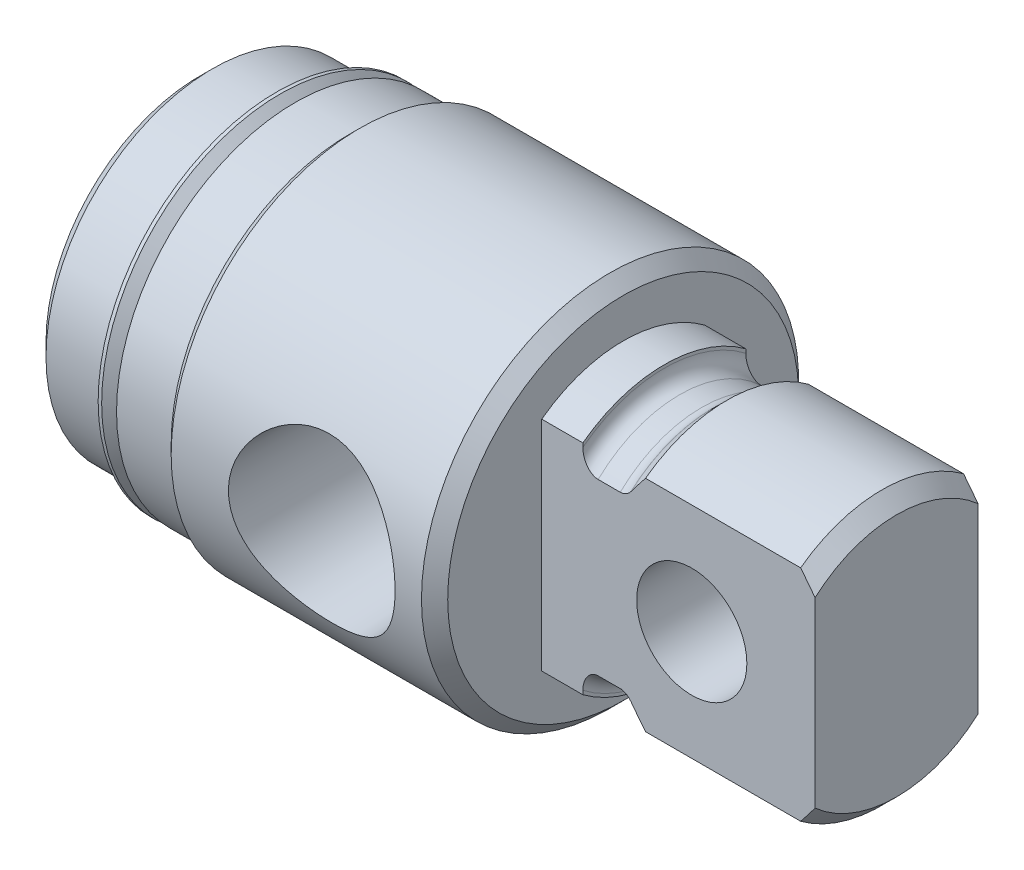
from build123d import *

# Parameters (mm, degrees)
SKETCH3_W               = 43.815
SKETCH3_H               = 87.63
SKETCH3_W_2             = 9.4615
SKETCH3_H_2             = 43.815
CUT_EXTRUDE1_DEPTH      = 15.875
HOLE1_D                 = 7.9248
HOLE1_DEPTH             = 23.58136
HOLE1_TIP               = 2.287692707
CUT_EXTRUDE2_DEPTH      = 7.096125
CUT_EXTRUDE2_DEPTH_BACK = 7.096125
SKETCH8_R               = 3.2004


with BuildPart() as part:
    # Sketch1 → Revolve1 (revolve)
    with BuildSketch(Plane.XY):
        Polygon((0, 0), (0, 8.90905), (0.762, 9.67105), (4.0386, 9.67105), (4.8006, 8.90905), (5.5626, 8.90905), (5.5626, 10.3759), (8.73633, 10.3759), (9.31418, 10.95375), (23.8506, 10.95375), (24.6126, 10.19175), (24.6126, 0), align=None)
    revolve(axis=Axis((24.6126, 0, 0), (-1, 0, 0)))

    # Sketch2 → Revolve2 (revolve)
    with BuildSketch(Plane.XY):
        with BuildLine():
            Line((24.6126, 0), (24.6126, 7.90575))
            Line((24.6126, 7.90575), (27.0002, 7.90575))
            Line((27.0002, 7.90575), (27.0002, 7.72795))
            ThreePointArc((27.0002, 7.72795), (27.260582072, 7.099332072), (27.8892, 6.83895))
            Line((27.8892, 6.83895), (29.1719, 6.83895))
            ThreePointArc((29.1719, 6.83895), (29.49290348, 6.898927826), (29.77059292, 7.0707683))
            Line((29.77059292, 7.0707683), (29.800517928, 7.09803))
            Line((29.800517928, 7.09803), (30.639987928, 7.9375))
            Line((30.639987928, 7.9375), (39.64813, 7.9375))
            Line((39.64813, 7.9375), (40.4876, 7.09803))
            Line((40.4876, 7.09803), (40.4876, 0))
            Line((40.4876, 0), (24.6126, 0))
        make_face()
    revolve(axis=Axis((40.4876, 0, 0), (-1, 0, 0)))

    # Sketch3 → Cut-Extrude1 (cut)
    with BuildSketch(Plane(origin=(40.4876, 0, 0), x_dir=(0, 0, -1), z_dir=(1, 0, 0))):
        Rectangle(SKETCH3_W, SKETCH3_H)
        Rectangle(SKETCH3_W_2, SKETCH3_H_2, mode=Mode.SUBTRACT)
    extrude(amount=-CUT_EXTRUDE1_DEPTH, mode=Mode.SUBTRACT)

    # Hole1
    with Locations(Plane.ZY):
        with Locations((0, 0)):
            Hole(HOLE1_D / 2, depth=HOLE1_DEPTH)
            with Locations((0, 0, -(HOLE1_DEPTH + HOLE1_TIP / 2))):  # 120° drill point
                Cone(0, HOLE1_D / 2, HOLE1_TIP, mode=Mode.SUBTRACT)

    # Sketch6 → Cut-Revolve1 (revolve, cut)
    with BuildSketch(Plane(origin=(0, 0, 0), x_dir=(1, 0, 0), z_dir=(0, 0.9998476951563913, 0.01745240643728403))):
        Polygon((17.4752, 0), (22.075197063, 0), (22.075197063, -3.28295), (22.314675925, -10.95375), (17.4752, -10.95375), align=None)
    revolve(axis=Axis((17.4752, -0.191169297, 10.952081691), (0, 0.01745240643728403, -0.9998476951563913)), mode=Mode.SUBTRACT)

    # Sketch7 → Revolve3 (revolve)
    with BuildSketch(Plane.XY):
        with BuildLine():
            Line((4.49554893, 10.291731804), (5.440112806, 9.347167928))
            ThreePointArc((5.440112806, 9.347167928), (5.477310245, 9.257365367), (5.440112806, 9.167562806))
            Line((5.440112806, 9.167562806), (5.1816, 8.90905))
            Line((5.1816, 8.90905), (4.8006, 8.90905))
            Line((4.8006, 8.90905), (4.8006, 8.65505))
            Line((4.8006, 8.65505), (5.5626, 8.65505))
            Line((5.5626, 8.65505), (5.5626, 9.51204893))
            Line((5.5626, 9.51204893), (4.69874893, 10.3759))
            Line((4.69874893, 10.3759), (4.49554893, 10.3759))
            Line((4.49554893, 10.3759), (4.49554893, 10.291731804))
        make_face()
    revolve(axis=Axis((5.5626, 0, 0), (-1, 0, 0)))

    # Sketch8 → Cut-Extrude2 (cut, two sides: drawn at the far end of the back side and taken through both)
    with BuildSketch(Plane.XY.offset(-CUT_EXTRUDE2_DEPTH_BACK)):
        with Locations((33.3248, 0)):
            Circle(SKETCH8_R)
    extrude(amount=CUT_EXTRUDE2_DEPTH + CUT_EXTRUDE2_DEPTH_BACK, mode=Mode.SUBTRACT)


solid = part.part
